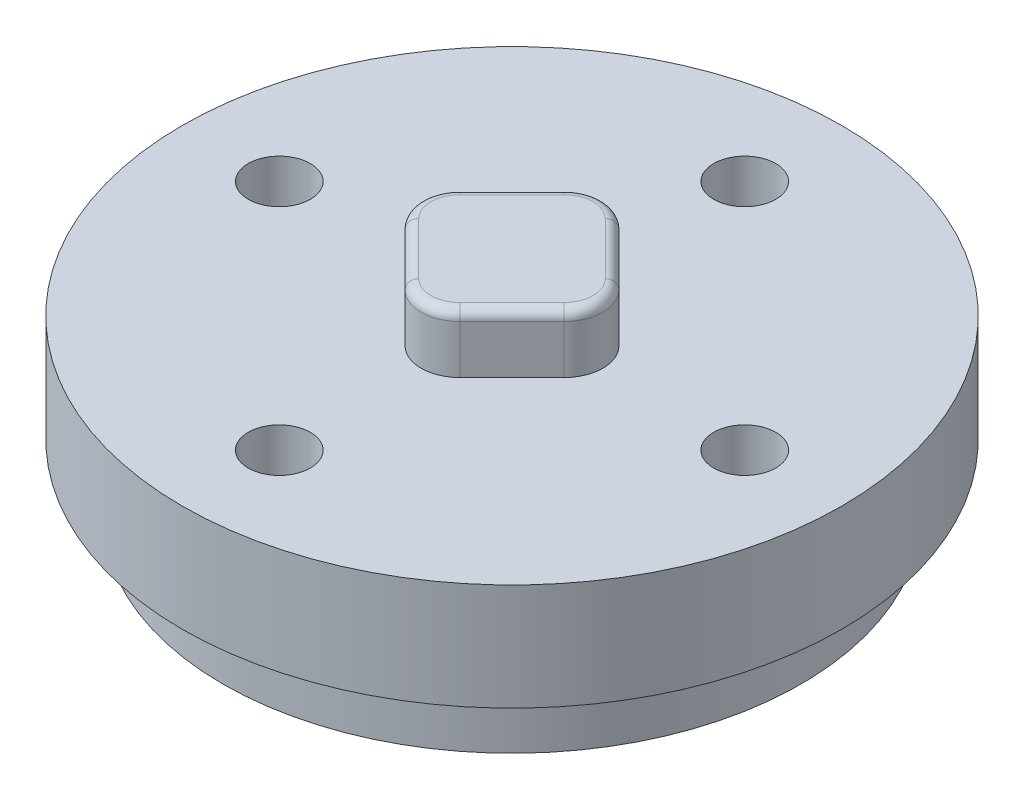
from build123d import *

# Parameters (mm, degrees)
SKETCH1_R           = 14.9
SKETCH1_R_2         = 1.6
BOSS_EXTRUDE1_DEPTH = 3.5
SKETCH2_R           = 1.5
BOSS_EXTRUDE2_DEPTH = 2
FILLET1_R           = 0.3
SKETCH3_R           = 17
SKETCH3_R_2         = 1.6
BOSS_EXTRUDE3_DEPTH = 5.5
BOSS_EXTRUDE4_DEPTH = 3
FILLET2_R           = 0.5


with BuildPart() as part:
    # Sketch1 → Boss-Extrude1 (new body)
    with BuildSketch(Plane(origin=(0, 0, 0), x_dir=(1, 0, 0), z_dir=(0, 1, 0))):
        Circle(SKETCH1_R)
        with Locations((0, 12)):
            Circle(SKETCH1_R_2, mode=Mode.SUBTRACT)
        with Locations((12, 0)):
            Circle(SKETCH1_R_2, mode=Mode.SUBTRACT)
        with Locations((0, -12)):
            Circle(SKETCH1_R_2, mode=Mode.SUBTRACT)
        with Locations((-12, 0)):
            Circle(SKETCH1_R_2, mode=Mode.SUBTRACT)
    extrude(amount=BOSS_EXTRUDE1_DEPTH)

    # Sketch2 → Boss-Extrude2 (add)
    with BuildSketch(Plane.XZ):
        with Locations((3.5, -3.5)):
            Circle(SKETCH2_R)
        with Locations((-3.5, 3.5)):
            Circle(SKETCH2_R)
    extrude(amount=BOSS_EXTRUDE2_DEPTH)

    # Fillet1
    fillet1_edges = [part.edges().sort_by_distance(p)[0] for p in [
        (2, -2, -3.5),
        (-5, -2, 3.5),
    ]]
    fillet(fillet1_edges, radius=FILLET1_R)

    # Sketch3 → Boss-Extrude3 (add)
    with BuildSketch(Plane(origin=(0, 3.5, 0), x_dir=(1, 0, 0), z_dir=(0, 1, 0))):
        Circle(SKETCH3_R)
        with Locations((12, 0)):
            Circle(SKETCH3_R_2, mode=Mode.SUBTRACT)
        with Locations((0, -12)):
            Circle(SKETCH3_R_2, mode=Mode.SUBTRACT)
        with Locations((-12, 0)):
            Circle(SKETCH3_R_2, mode=Mode.SUBTRACT)
        with Locations((0, 12)):
            Circle(SKETCH3_R_2, mode=Mode.SUBTRACT)
    extrude(amount=BOSS_EXTRUDE3_DEPTH)

    # Sketch4 → Boss-Extrude4 (add)
    with BuildSketch(Plane(origin=(0, 9, 0), x_dir=(1, 0, 0), z_dir=(0, 1, 0))):
        with BuildLine():
            Line((-4.101219331, 1.414213562), (-1.414213562, 4.101219331))
            ThreePointArc((-1.414213562, 4.101219331), (0, 4.687005769), (1.414213562, 4.101219331))
            Line((1.414213562, 4.101219331), (4.101219331, 1.414213562))
            ThreePointArc((4.101219331, 1.414213562), (4.687005769, 0), (4.101219331, -1.414213562))
            Line((4.101219331, -1.414213562), (1.414213562, -4.101219331))
            ThreePointArc((1.414213562, -4.101219331), (0, -4.687005769), (-1.414213562, -4.101219331))
            Line((-1.414213562, -4.101219331), (-4.101219331, -1.414213562))
            ThreePointArc((-4.101219331, -1.414213562), (-4.687005769, 0), (-4.101219331, 1.414213562))
        make_face()
    extrude(amount=BOSS_EXTRUDE4_DEPTH)

    # Fillet2
    fillet2_edges = [part.edges().sort_by_distance(p)[0] for p in [
        (4.687005769, 12, 0),
        (2.757716447, 12, -2.757716447),
        (0, 12, -4.687005769),
        (-2.757716447, 12, -2.757716447),
        (-4.687005769, 12, 0),
        (-2.757716447, 12, 2.757716447),
        (0, 12, 4.687005769),
        (2.757716447, 12, 2.757716447),
    ]]
    fillet(fillet2_edges, radius=FILLET2_R)


solid = part.part
